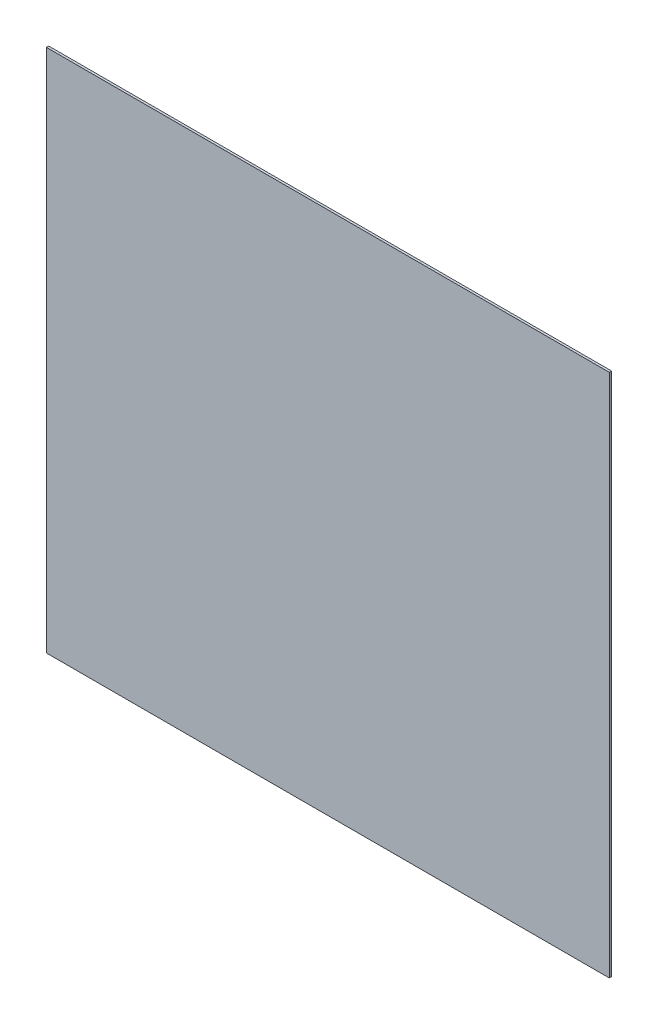
from build123d import *

# Parameters (mm, degrees)
SKETCH1_W           = 778
SKETCH1_H           = 725
BOSS_EXTRUDE1_DEPTH = 3.175


with BuildPart() as part:
    # Sketch1 → Boss-Extrude1 (new body)
    with BuildSketch(Plane.XY):
        Rectangle(SKETCH1_W, SKETCH1_H)
    extrude(amount=BOSS_EXTRUDE1_DEPTH)


solid = part.part
